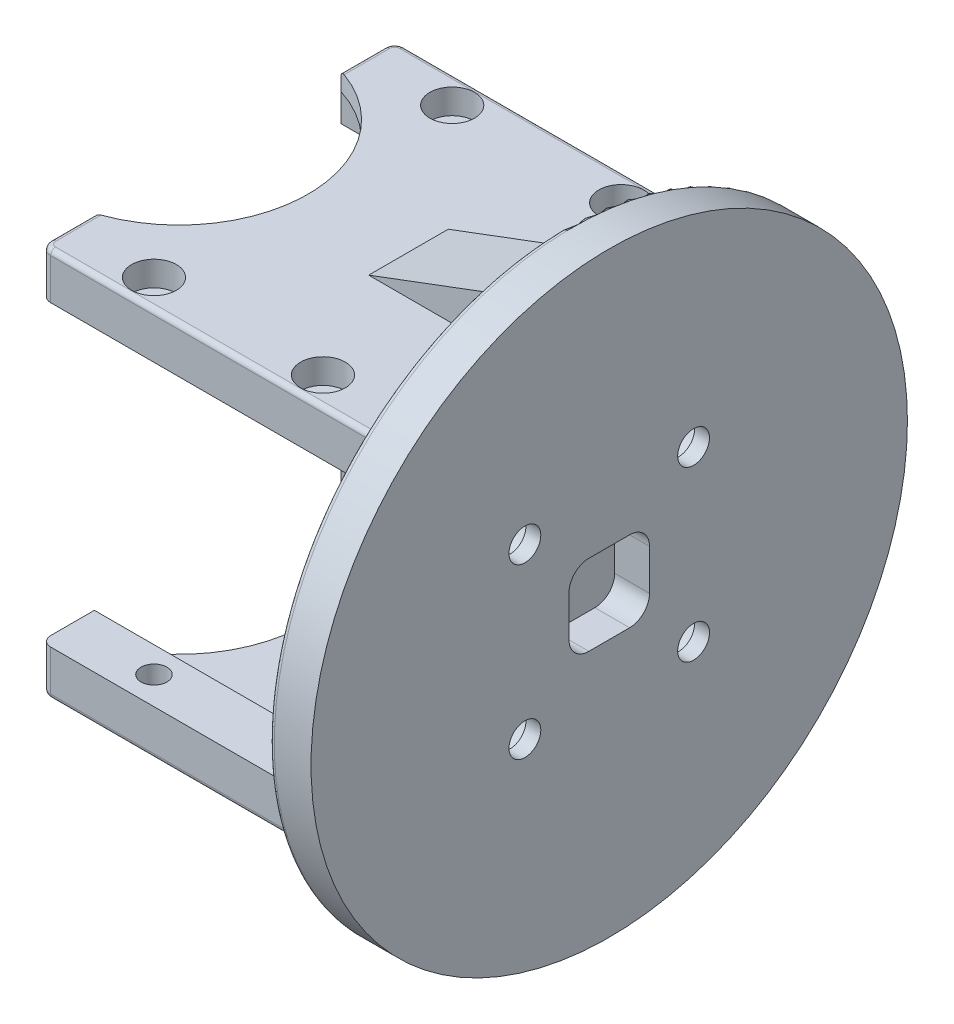
from build123d import *

# Parameters (mm, degrees)
SKETCH1_R           = 1.3
BOSS_EXTRUDE1_DEPTH = 2.8
SKETCH2_R           = 1.3
BOSS_EXTRUDE2_DEPTH = 1.8
SKETCH3_R           = 2.25
CUT_EXTRUDE1_DEPTH  = 2.5
SKETCH4_W           = 35.6
SKETCH4_H           = 4.6
BOSS_EXTRUDE3_DEPTH = 5
SKETCH5_W           = 4.2
SKETCH5_H           = 35.6
BOSS_EXTRUDE4_DEPTH = 15
FILLET1_R           = 1
SKETCH6_R           = 1.6
CUT_EXTRUDE2_DEPTH  = 40.396155741
SKETCH7_R           = 2.8
CUT_EXTRUDE3_DEPTH  = 2.7
CUT_EXTRUDE4_DEPTH  = 3.5
SKETCH9_R           = 30
SKETCH9_W           = 35.6
SKETCH9_H           = 39.2
BOSS_EXTRUDE5_DEPTH = 4.2
BOSS_EXTRUDE6_DEPTH = 4
FILLET2_R           = 0.5
FILLET3_R           = 0.5


with BuildPart() as part:
    # Sketch1 → Boss-Extrude1 (new body)
    with BuildSketch(Plane(origin=(0, 0, 0), x_dir=(1, 0, 0), z_dir=(0, 1, 0))):
        Polygon((33.2, 12.4), (33.2, -12.4), (3.903844259, -12.4), (3.903844259, -17.8), (38.3, -17.8), (38.3, 17.8), (3.903844259, 17.8), (3.903844259, 12.4), align=None)
        with Locations((12.5, 15)):
            Circle(SKETCH1_R, mode=Mode.SUBTRACT)
        with Locations((29.5, 15)):
            Circle(SKETCH1_R, mode=Mode.SUBTRACT)
        with Locations((29.5, -15)):
            Circle(SKETCH1_R, mode=Mode.SUBTRACT)
        with Locations((12.5, -15)):
            Circle(SKETCH1_R, mode=Mode.SUBTRACT)
        with Locations((35.8, -8.5)):
            Circle(SKETCH1_R, mode=Mode.SUBTRACT)
        with Locations((35.8, 8.5)):
            Circle(SKETCH1_R, mode=Mode.SUBTRACT)
    extrude(amount=BOSS_EXTRUDE1_DEPTH)

    # Sketch2 → Boss-Extrude2 (add)
    with BuildSketch(Plane(origin=(0, 2.8, 0), x_dir=(1, 0, 0), z_dir=(0, 1, 0))):
        with BuildLine():
            Line((3.903844259, -12.4), (3.903844259, -17.8))
            Line((3.903844259, -17.8), (38.3, -17.8))
            Line((38.3, -17.8), (38.3, 17.8))
            Line((38.3, 17.8), (3.903844259, 17.8))
            Line((3.903844259, 17.8), (3.903844259, 12.4))
            ThreePointArc((3.903844259, 12.4), (13, 0), (3.903844259, -12.4))
        make_face()
        with Locations((12.5, -15)):
            Circle(SKETCH2_R, mode=Mode.SUBTRACT)
        with Locations((29.5, -15)):
            Circle(SKETCH2_R, mode=Mode.SUBTRACT)
        with Locations((35.8, -8.5)):
            Circle(SKETCH2_R, mode=Mode.SUBTRACT)
        with Locations((35.8, 8.5)):
            Circle(SKETCH2_R, mode=Mode.SUBTRACT)
        with Locations((29.5, 15)):
            Circle(SKETCH2_R, mode=Mode.SUBTRACT)
        with Locations((12.5, 15)):
            Circle(SKETCH2_R, mode=Mode.SUBTRACT)
    extrude(amount=BOSS_EXTRUDE2_DEPTH)

    # Sketch3 → Cut-Extrude1 (cut)
    with BuildSketch(Plane(origin=(0, 4.6, 0), x_dir=(1, 0, 0), z_dir=(0, 1, 0))):
        with Locations((12.5, 15)):
            Circle(SKETCH3_R)
        with Locations((29.5, 15)):
            Circle(SKETCH3_R)
        with Locations((35.8, 8.5)):
            Circle(SKETCH3_R)
        with Locations((35.8, -8.5)):
            Circle(SKETCH3_R)
        with Locations((29.5, -15)):
            Circle(SKETCH3_R)
        with Locations((12.5, -15)):
            Circle(SKETCH3_R)
    extrude(amount=-CUT_EXTRUDE1_DEPTH, mode=Mode.SUBTRACT)

    # Sketch4 → Boss-Extrude3 (add)
    with BuildSketch(Plane(origin=(38.3, 0, 0), x_dir=(0, 0, -1), z_dir=(1, 0, 0))):
        with Locations((0, 2.3)):
            Rectangle(SKETCH4_W, SKETCH4_H)
    extrude(amount=BOSS_EXTRUDE3_DEPTH)

    # Sketch5 → Boss-Extrude4 (add)
    with BuildSketch(Plane.XZ):
        with Locations((41.2, 0)):
            Rectangle(SKETCH5_W, SKETCH5_H)
    extrude(amount=BOSS_EXTRUDE4_DEPTH)

    # Mirror1: part across plane


with BuildPart() as part_1:
    add(part.part)
    add(part.part.mirror(Plane.ZX.offset(-15)))

    # Fillet1
    fillet1_edges = [part_1.edges().sort_by_distance(p)[0] for p in [
        (3.903844259, 2.3, -17.8),
        (3.903844259, 2.3, 17.8),
        (3.903844259, -32.3, 17.8),
        (3.903844259, -32.3, -17.8),
    ]]
    fillet(fillet1_edges, radius=FILLET1_R)

    # Sketch6 → Cut-Extrude2 (cut, through all)
    with BuildSketch(Plane(origin=(43.3, 0, 0), x_dir=(0, 0, -1), z_dir=(1, 0, 0))):
        with Locations((8.485281374, -23.485281374)):
            Circle(SKETCH6_R)
        with Locations((-8.485281374, -23.485281374)):
            Circle(SKETCH6_R)
        with Locations((-8.485281374, -6.514718626)):
            Circle(SKETCH6_R)
        with Locations((8.485281374, -6.514718626)):
            Circle(SKETCH6_R)
    extrude(amount=-CUT_EXTRUDE2_DEPTH, mode=Mode.SUBTRACT)

    # Sketch7 → Cut-Extrude3 (cut)
    with BuildSketch(Plane.ZY.offset(-39.1)):
        with Locations((-8.485281374, -6.514718626)):
            Circle(SKETCH7_R)
        with Locations((8.485281374, -6.514718626)):
            Circle(SKETCH7_R)
        with Locations((-8.485281374, -23.485281374)):
            Circle(SKETCH7_R)
        with Locations((8.485281374, -23.485281374)):
            Circle(SKETCH7_R)
    extrude(amount=-CUT_EXTRUDE3_DEPTH, mode=Mode.SUBTRACT)

    # Sketch8 → Cut-Extrude4 (cut)
    with BuildSketch(Plane(origin=(43.3, 0, 0), x_dir=(0, 0, -1), z_dir=(1, 0, 0))):
        with BuildLine():
            Line((-2.05, -19.05), (2.05, -19.05))
            ThreePointArc((2.05, -19.05), (3.464213562, -18.464213562), (4.05, -17.05))
            Line((4.05, -17.05), (4.05, -12.95))
            ThreePointArc((4.05, -12.95), (3.464213562, -11.535786438), (2.05, -10.95))
            Line((2.05, -10.95), (-2.05, -10.95))
            ThreePointArc((-2.05, -10.95), (-3.464213562, -11.535786438), (-4.05, -12.95))
            Line((-4.05, -12.95), (-4.05, -17.05))
            ThreePointArc((-4.05, -17.05), (-3.464213562, -18.464213562), (-2.05, -19.05))
        make_face()
    extrude(amount=-CUT_EXTRUDE4_DEPTH, mode=Mode.SUBTRACT)

    # Sketch9 → Boss-Extrude5 (add)
    with BuildSketch(Plane(origin=(43.3, 0, 0), x_dir=(0, 0, -1), z_dir=(1, 0, 0))):
        with Locations((0, -15)):
            Circle(SKETCH9_R)
        with Locations((0, -15)):
            Rectangle(SKETCH9_W, SKETCH9_H, mode=Mode.SUBTRACT)
    extrude(amount=-BOSS_EXTRUDE5_DEPTH)

    # Sketch10 → Boss-Extrude6 (add, symmetric)
    with BuildSketch(Plane.XY):
        Polygon((39.1, 10.6), (39.1, 4.6), (23.1, 4.6), align=None)
    boss_extrude6 = extrude(amount=BOSS_EXTRUDE6_DEPTH, both=True)

    # Mirror2: Boss-Extrude6 across plane
    add(boss_extrude6.mirror(Plane(origin=(0, -15, 0), x_dir=(0, 0, 1), z_dir=(0, -1, 0))))

    # Fillet2
    fillet2_edges = [part_1.edges().sort_by_distance(p)[0] for p in [
        (39.1, -15, 30),
    ]]
    fillet(fillet2_edges, radius=FILLET2_R)

    # Fillet3
    fillet3_edges = [part_1.edges().sort_by_distance(p)[0] for p in [
        (3.903844259, -34.6, 14.6),
        (3.903844259, 4.6, -14.6),
        (22.00192213, 4.6, 17.8),
        (4.196737478, 4.6, 17.507106781),
        (4.196737478, 4.6, -17.507106781),
        (3.903844259, -34.6, -14.6),
        (22.00192213, -34.6, 17.8),
        (4.196737478, -34.6, 17.507106781),
        (4.196737478, -34.6, -17.507106781),
        (22.00192213, -34.6, -17.8),
        (22.00192213, 4.6, -17.8),
        (39.1, -32.3, 17.8),
        (39.1, 2.3, 17.8),
        (39.1, -34.6, -10.9),
        (39.1, 2.3, -17.8),
        (39.1, -32.3, -17.8),
        (39.1, 4.6, 10.9),
        (39.1, 4.6, -10.9),
        (39.1, 10.6, 0),
        (39.1, 7.6, -4),
        (39.1, 7.6, 4),
        (39.1, -34.6, 10.9),
        (39.1, -37.6, 4),
        (39.1, -40.6, 0),
        (39.1, -37.6, -4),
        (3.903844259, 4.6, 14.6),
    ]]
    fillet(fillet3_edges, radius=FILLET3_R)


solid = part_1.part
